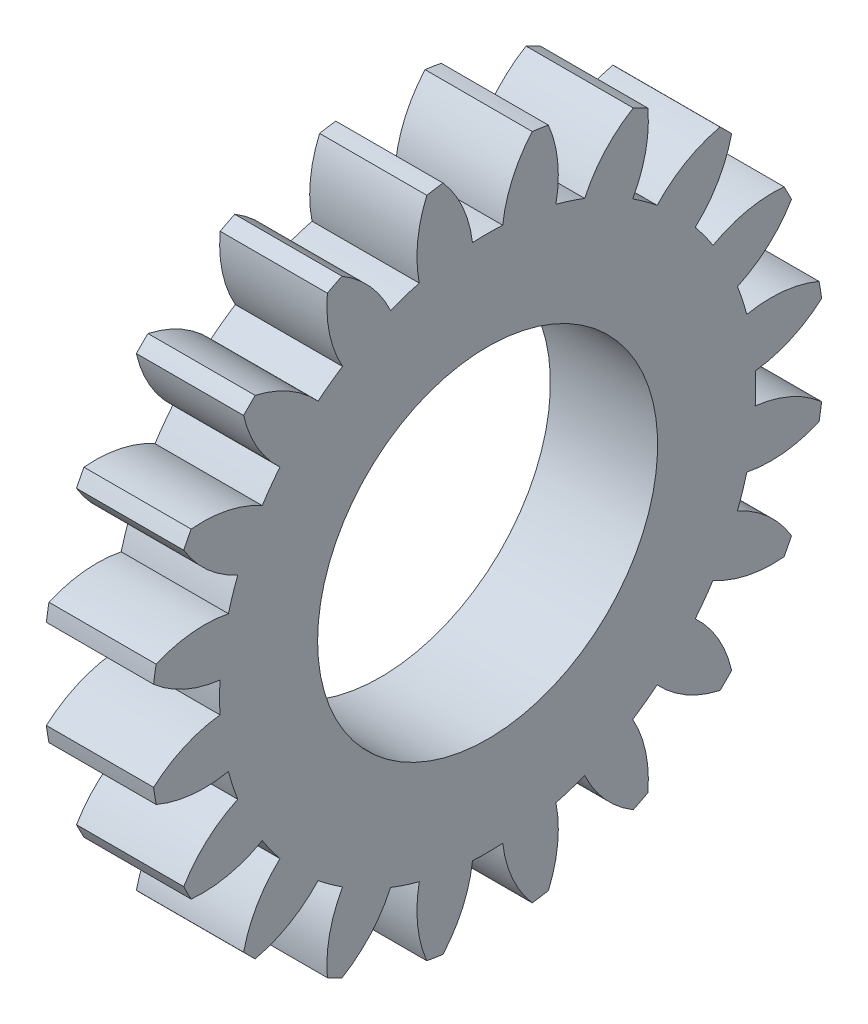
from build123d import *

# Parameters (mm, degrees)
BASPROSKE_W        = 15
BASPROSKE_H        = 22
TOOTHCUT_DEPTH     = 35.539832078
TEETHCUTS_COUNT    = 20
TEETHCUTS_ANGLE    = 342
BORSKE_R           = 0.5
BORE_DEPTH         = 50.0000508
SKETCH1_R          = 11.1
CUT_EXTRUDE1_DEPTH = 16
CUT_EXTRUDE2_DEPTH = 8


with BuildPart() as part:
    # BasProSke → Base-Revolve (revolve)
    with BuildSketch(Plane(origin=(0, 0, 0), x_dir=(1, 0, 0), z_dir=(0, 1, 0)), mode=Mode.PRIVATE) as base_revolve_sk:
        with Locations((7.5, 11)):
            Rectangle(BASPROSKE_W, BASPROSKE_H)
    revolve(base_revolve_sk.sketch.rotate(Axis((-10, 0, 0), (1, 0, 0)), 180), axis=Axis((-10, 0, 0), (1, 0, 0)))

    # TooCutSke → ToothCut (cut, through all)
    with BuildSketch(Plane(origin=(0, 0, 0), x_dir=(0, 0, -1), z_dir=(1, 0, 0))):
        with BuildLine():
            ThreePointArc((0.986171591, 17.471189616), (0, 17.499), (-0.986171591, 17.471189616))
            ThreePointArc((-0.986171591, 17.471189616), (-1.626916196, 19.798789858), (-2.932850173, 21.829260982))
            ThreePointArc((-2.932850173, 21.829260982), (0, 22.0254), (2.932850173, 21.829260982))
            ThreePointArc((2.932850173, 21.829260982), (1.626916196, 19.798789858), (0.986171591, 17.471189616))
        make_face()
    toothcut = extrude(amount=TOOTHCUT_DEPTH, mode=Mode.SUBTRACT)

    # TeethCuts: ToothCut ×20 about axis
    teethcuts_axis = Axis((-10, 0, 0), (1, 0, 0))
    for i in range(1, TEETHCUTS_COUNT):
        add(toothcut.rotate(teethcuts_axis, i * TEETHCUTS_ANGLE / (TEETHCUTS_COUNT - 1)), mode=Mode.SUBTRACT)

    # BorSke → Bore (cut, symmetric)
    with BuildSketch(Plane(origin=(0, 0, 0), x_dir=(0, 0, -1), z_dir=(1, 0, 0))):
        with Locations(Location((0, 0, 0), (0, 0, 180))):
            Circle(BORSKE_R)
    extrude(amount=BORE_DEPTH, both=True, mode=Mode.SUBTRACT)

    # Sketch1 → Cut-Extrude1 (cut)
    with BuildSketch(Plane.ZY):
        Circle(SKETCH1_R)
    extrude(amount=-CUT_EXTRUDE1_DEPTH, mode=Mode.SUBTRACT)

    # Sketch2 → Cut-Extrude2 (cut)
    with BuildSketch(Plane.ZY):
        with BuildLine():
            ThreePointArc((17.471189616, 0.986171591), (19.784848102, 1.620704589), (21.806333941, 2.912696354))
            ThreePointArc((21.806333941, 2.912696354), (21.729143493, 3.441558231), (21.639128664, 3.968388926))
            ThreePointArc((21.639128664, 3.968388926), (19.317333972, 4.572472634), (16.920832513, 4.460989585))
            ThreePointArc((16.920832513, 4.460989585), (16.642537979, 5.407488385), (16.31134495, 6.336799421))
            ThreePointArc((16.31134495, 6.336799421), (18.31568345, 7.655235955), (19.838983319, 9.50866662))
            ThreePointArc((19.838983319, 9.50866662), (19.602143532, 9.987790994), (19.353734704, 10.461020648))
            ThreePointArc((19.353734704, 10.461020648), (16.958904602, 10.318064378), (14.714146429, 9.471478019))
            ThreePointArc((14.714146429, 9.471478019), (14.156988385, 10.28565413), (13.554832194, 11.067137173))
            ThreePointArc((13.554832194, 11.067137173), (15.05365209, 12.940419489), (15.929654782, 15.173862347))
            ThreePointArc((15.929654782, 15.173862347), (15.556349186, 15.556349186), (15.173862347, 15.929654782))
            ThreePointArc((15.173862347, 15.929654782), (12.940419489, 15.05365209), (11.067137173, 13.554832194))
            ThreePointArc((11.067137173, 13.554832194), (10.28565413, 14.156988385), (9.471478019, 14.714146429))
            ThreePointArc((9.471478019, 14.714146429), (10.318064378, 16.958904602), (10.461020648, 19.353734704))
            ThreePointArc((10.461020648, 19.353734704), (9.987790994, 19.602143532), (9.50866662, 19.838983319))
            ThreePointArc((9.50866662, 19.838983319), (7.655235955, 18.31568345), (6.336799421, 16.31134495))
            ThreePointArc((6.336799421, 16.31134495), (5.407488385, 16.642537979), (4.460989585, 16.920832513))
            ThreePointArc((4.460989585, 16.920832513), (4.572472634, 19.317333972), (3.968388926, 21.639128664))
            ThreePointArc((3.968388926, 21.639128664), (3.441558231, 21.729143493), (2.912696354, 21.806333941))
            ThreePointArc((2.912696354, 21.806333941), (1.620704589, 19.784848102), (0.986171591, 17.471189616))
            ThreePointArc((0.986171591, 17.471189616), (0, 17.499), (-0.986171591, 17.471189616))
            ThreePointArc((-0.986171591, 17.471189616), (-1.620704589, 19.784848102), (-2.912696354, 21.806333941))
            ThreePointArc((-2.912696354, 21.806333941), (-3.441558231, 21.729143493), (-3.968388926, 21.639128664))
            ThreePointArc((-3.968388926, 21.639128664), (-4.572472634, 19.317333972), (-4.460989585, 16.920832513))
            ThreePointArc((-4.460989585, 16.920832513), (-5.407488385, 16.642537979), (-6.336799421, 16.31134495))
            ThreePointArc((-6.336799421, 16.31134495), (-7.655235955, 18.31568345), (-9.50866662, 19.838983319))
            ThreePointArc((-9.50866662, 19.838983319), (-9.987790994, 19.602143532), (-10.461020648, 19.353734704))
            ThreePointArc((-10.461020648, 19.353734704), (-10.318064378, 16.958904602), (-9.471478019, 14.714146429))
            ThreePointArc((-9.471478019, 14.714146429), (-10.28565413, 14.156988385), (-11.067137173, 13.554832194))
            ThreePointArc((-11.067137173, 13.554832194), (-12.940419489, 15.05365209), (-15.173862347, 15.929654782))
            ThreePointArc((-15.173862347, 15.929654782), (-15.556349186, 15.556349186), (-15.929654782, 15.173862347))
            ThreePointArc((-15.929654782, 15.173862347), (-15.05365209, 12.940419489), (-13.554832194, 11.067137173))
            ThreePointArc((-13.554832194, 11.067137173), (-14.156988385, 10.28565413), (-14.714146429, 9.471478019))
            ThreePointArc((-14.714146429, 9.471478019), (-16.958904602, 10.318064378), (-19.353734704, 10.461020648))
            ThreePointArc((-19.353734704, 10.461020648), (-19.602143532, 9.987790994), (-19.838983319, 9.50866662))
            ThreePointArc((-19.838983319, 9.50866662), (-18.31568345, 7.655235955), (-16.31134495, 6.336799421))
            ThreePointArc((-16.31134495, 6.336799421), (-16.642537979, 5.407488385), (-16.920832513, 4.460989585))
            ThreePointArc((-16.920832513, 4.460989585), (-19.317333972, 4.572472634), (-21.639128664, 3.968388926))
            ThreePointArc((-21.639128664, 3.968388926), (-21.729143493, 3.441558231), (-21.806333941, 2.912696354))
            ThreePointArc((-21.806333941, 2.912696354), (-19.784848102, 1.620704589), (-17.471189616, 0.986171591))
            ThreePointArc((-17.471189616, 0.986171591), (-17.499, 0), (-17.471189616, -0.986171591))
            ThreePointArc((-17.471189616, -0.986171591), (-19.784848102, -1.620704589), (-21.806333941, -2.912696354))
            ThreePointArc((-21.806333941, -2.912696354), (-21.729143493, -3.441558231), (-21.639128664, -3.968388926))
            ThreePointArc((-21.639128664, -3.968388926), (-19.317333972, -4.572472634), (-16.920832513, -4.460989585))
            ThreePointArc((-16.920832513, -4.460989585), (-16.642537979, -5.407488385), (-16.31134495, -6.336799421))
            ThreePointArc((-16.31134495, -6.336799421), (-18.31568345, -7.655235955), (-19.838983319, -9.50866662))
            ThreePointArc((-19.838983319, -9.50866662), (-19.602143532, -9.987790994), (-19.353734704, -10.461020648))
            ThreePointArc((-19.353734704, -10.461020648), (-16.958904602, -10.318064378), (-14.714146429, -9.471478019))
            ThreePointArc((-14.714146429, -9.471478019), (-14.156988385, -10.28565413), (-13.554832194, -11.067137173))
            ThreePointArc((-13.554832194, -11.067137173), (-15.05365209, -12.940419489), (-15.929654782, -15.173862347))
            ThreePointArc((-15.929654782, -15.173862347), (-15.556349186, -15.556349186), (-15.173862347, -15.929654782))
            ThreePointArc((-15.173862347, -15.929654782), (-12.940419489, -15.05365209), (-11.067137173, -13.554832194))
            ThreePointArc((-11.067137173, -13.554832194), (-10.28565413, -14.156988385), (-9.471478019, -14.714146429))
            ThreePointArc((-9.471478019, -14.714146429), (-10.318064378, -16.958904602), (-10.461020648, -19.353734704))
            ThreePointArc((-10.461020648, -19.353734704), (-9.987790994, -19.602143532), (-9.50866662, -19.838983319))
            ThreePointArc((-9.50866662, -19.838983319), (-7.655235955, -18.31568345), (-6.336799421, -16.31134495))
            ThreePointArc((-6.336799421, -16.31134495), (-5.407488385, -16.642537979), (-4.460989585, -16.920832513))
            ThreePointArc((-4.460989585, -16.920832513), (-4.572472634, -19.317333972), (-3.968388926, -21.639128664))
            ThreePointArc((-3.968388926, -21.639128664), (-3.441558231, -21.729143493), (-2.912696354, -21.806333941))
            ThreePointArc((-2.912696354, -21.806333941), (-1.620704589, -19.784848102), (-0.986171591, -17.471189616))
            ThreePointArc((-0.986171591, -17.471189616), (0, -17.499), (0.986171591, -17.471189616))
            ThreePointArc((0.986171591, -17.471189616), (1.620704589, -19.784848102), (2.912696354, -21.806333941))
            ThreePointArc((2.912696354, -21.806333941), (3.441558231, -21.729143493), (3.968388926, -21.639128664))
            ThreePointArc((3.968388926, -21.639128664), (4.572472634, -19.317333972), (4.460989585, -16.920832513))
            ThreePointArc((4.460989585, -16.920832513), (5.407488385, -16.642537979), (6.336799421, -16.31134495))
            ThreePointArc((6.336799421, -16.31134495), (7.655235955, -18.31568345), (9.50866662, -19.838983319))
            ThreePointArc((9.50866662, -19.838983319), (9.987790994, -19.602143532), (10.461020648, -19.353734704))
            ThreePointArc((10.461020648, -19.353734704), (10.318064378, -16.958904602), (9.471478019, -14.714146429))
            ThreePointArc((9.471478019, -14.714146429), (10.28565413, -14.156988385), (11.067137173, -13.554832194))
            ThreePointArc((11.067137173, -13.554832194), (12.940419489, -15.05365209), (15.173862347, -15.929654782))
            ThreePointArc((15.173862347, -15.929654782), (15.556349186, -15.556349186), (15.929654782, -15.173862347))
            ThreePointArc((15.929654782, -15.173862347), (15.05365209, -12.940419489), (13.554832194, -11.067137173))
            ThreePointArc((13.554832194, -11.067137173), (14.156988385, -10.28565413), (14.714146429, -9.471478019))
            ThreePointArc((14.714146429, -9.471478019), (16.958904602, -10.318064378), (19.353734704, -10.461020648))
            ThreePointArc((19.353734704, -10.461020648), (19.602143532, -9.987790994), (19.838983319, -9.50866662))
            ThreePointArc((19.838983319, -9.50866662), (18.31568345, -7.655235955), (16.31134495, -6.336799421))
            ThreePointArc((16.31134495, -6.336799421), (16.642537979, -5.407488385), (16.920832513, -4.460989585))
            ThreePointArc((16.920832513, -4.460989585), (19.317333972, -4.572472634), (21.639128664, -3.968388926))
            ThreePointArc((21.639128664, -3.968388926), (21.729143493, -3.441558231), (21.806333941, -2.912696354))
            ThreePointArc((21.806333941, -2.912696354), (19.784848102, -1.620704589), (17.471189616, -0.986171591))
            ThreePointArc((17.471189616, -0.986171591), (17.499, 0), (17.471189616, 0.986171591))
        make_face()
    extrude(amount=-CUT_EXTRUDE2_DEPTH, mode=Mode.SUBTRACT)


solid = part.part
